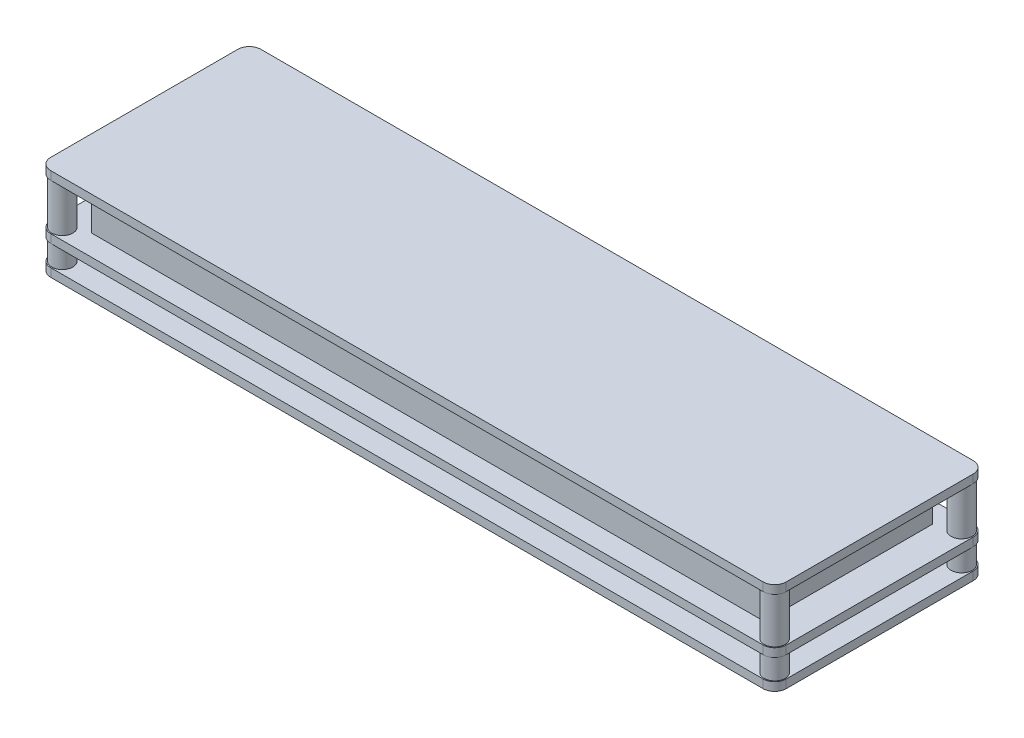
from build123d import *

# Parameters (mm, degrees)
SKETCH1_W                                  = 175
SKETCH1_H                                  = 50
BOSS_EXTRUDE1_DEPTH                        = 2
BOSS_EXTRUDE2_START                        = 11
SKETCH2_W                                  = 175
SKETCH2_H                                  = 50
BOSS_EXTRUDE2_DEPTH                        = 2
BOSS_EXTRUDE3_START                        = 5
SKETCH3_W                                  = 175
SKETCH3_H                                  = 50
BOSS_EXTRUDE3_DEPTH                        = 2
SKETCH5_W                                  = 160
SKETCH5_H                                  = 40
BOSS_EXTRUDE4_DEPTH                        = 10
SKETCH7_W                                  = 5
SKETCH7_H                                  = 35
CUT_EXTRUDE1_DEPTH                         = 0.1
LPATTERN1_COUNT                            = 16
LPATTERN1_PITCH                            = 10
SKETCH8_R                                  = 2.5
BOSS_EXTRUDE5_DEPTH                        = 18
MIRROR1_AT_THE_SECOND_PLANE_COPY_1_SKETC_R = 2.5
MIRROR1_AT_THE_SECOND_PLANE_COPY_1_DEPTH   = 18
FILLET2_R                                  = 2.75


with BuildPart() as part:
    # Sketch1 → Boss-Extrude1 (new body)
    with BuildSketch(Plane(origin=(0, 0, 0), x_dir=(1, 0, 0), z_dir=(0, 1, 0))):
        Rectangle(SKETCH1_W, SKETCH1_H)
    extrude(amount=BOSS_EXTRUDE1_DEPTH)

    # Sketch5 → Boss-Extrude4 (add)
    with BuildSketch(Plane(origin=(0, 2, 0), x_dir=(1, 0, 0), z_dir=(0, 1, 0))):
        Rectangle(SKETCH5_W, SKETCH5_H)
    extrude(amount=BOSS_EXTRUDE4_DEPTH)

    # Sketch7 → Cut-Extrude1 (cut)
    with BuildSketch(Plane(origin=(0, 12, 0), x_dir=(1, 0, 0), z_dir=(0, 1, 0))):
        with Locations((-75, 0)):
            Rectangle(SKETCH7_W, SKETCH7_H)
    cut_extrude1 = extrude(amount=-CUT_EXTRUDE1_DEPTH, mode=Mode.SUBTRACT)

    # LPattern1: Cut-Extrude1 ×16
    with Locations(*[(i * LPATTERN1_PITCH, 0, 0) for i in range(1, LPATTERN1_COUNT)]):
        add(cut_extrude1, mode=Mode.SUBTRACT)



with BuildPart() as body_2:
    # Sketch2 → Boss-Extrude2 (new body)
    with BuildSketch(Plane(origin=(0, 2, 0), x_dir=(1, 0, 0), z_dir=(0, 1, 0)).offset(BOSS_EXTRUDE2_START)):
        Rectangle(SKETCH2_W, SKETCH2_H)
    extrude(amount=BOSS_EXTRUDE2_DEPTH)


with BuildPart() as body_3:
    # Sketch3 → Boss-Extrude3 (new body)
    with BuildSketch(Plane.XZ.offset(BOSS_EXTRUDE3_START)):
        Rectangle(SKETCH3_W, SKETCH3_H)
    extrude(amount=BOSS_EXTRUDE3_DEPTH)


with BuildPart() as part_1:
    add(part.part)

    add(body_2.part)  # Boss-Extrude5 merges body 2

    add(body_3.part)  # Boss-Extrude5 merges body 3
    # Sketch8 → Boss-Extrude5 (add)
    with BuildSketch(Plane(origin=(0, -5, 0), x_dir=(1, 0, 0), z_dir=(0, 1, 0))):
        with Locations((-84.75, 22.25)):
            Circle(SKETCH8_R)
    boss_extrude5 = extrude(amount=BOSS_EXTRUDE5_DEPTH)

    # Mirror1: Boss-Extrude5 across plane
    add(boss_extrude5.mirror(Plane(origin=(0, 0, 0), x_dir=(0, 0, 1), z_dir=(1, 0, 0))))

    # Mirror1 at the second plane: Boss-Extrude5 across plane
    add(boss_extrude5.mirror(Plane.XY))

    # Mirror1 at the second plane copy 1 sketc → Mirror1 at the second plane copy 1 (add)
    with BuildSketch(Plane(origin=(0, -5, 0), x_dir=(-1, 0, 0), z_dir=(0, 1, 0))):
        with Locations((-84.75, 22.25)):
            Circle(MIRROR1_AT_THE_SECOND_PLANE_COPY_1_SKETC_R)
    extrude(amount=MIRROR1_AT_THE_SECOND_PLANE_COPY_1_DEPTH)

    # Fillet2
    fillet2_edges = [part_1.edges().sort_by_distance(p)[0] for p in [
        (87.5, -6, 25),
        (-87.5, -6, 25),
        (-87.5, -6, -25),
        (87.5, -6, -25),
        (-87.5, 1, -25),
        (-87.5, 1, 25),
        (87.5, 1, 25),
        (87.5, 1, -25),
        (87.5, 14, -25),
        (87.5, 14, 25),
        (-87.5, 14, 25),
        (-87.5, 14, -25),
    ]]
    fillet(fillet2_edges, radius=FILLET2_R)


solid = part_1.part
